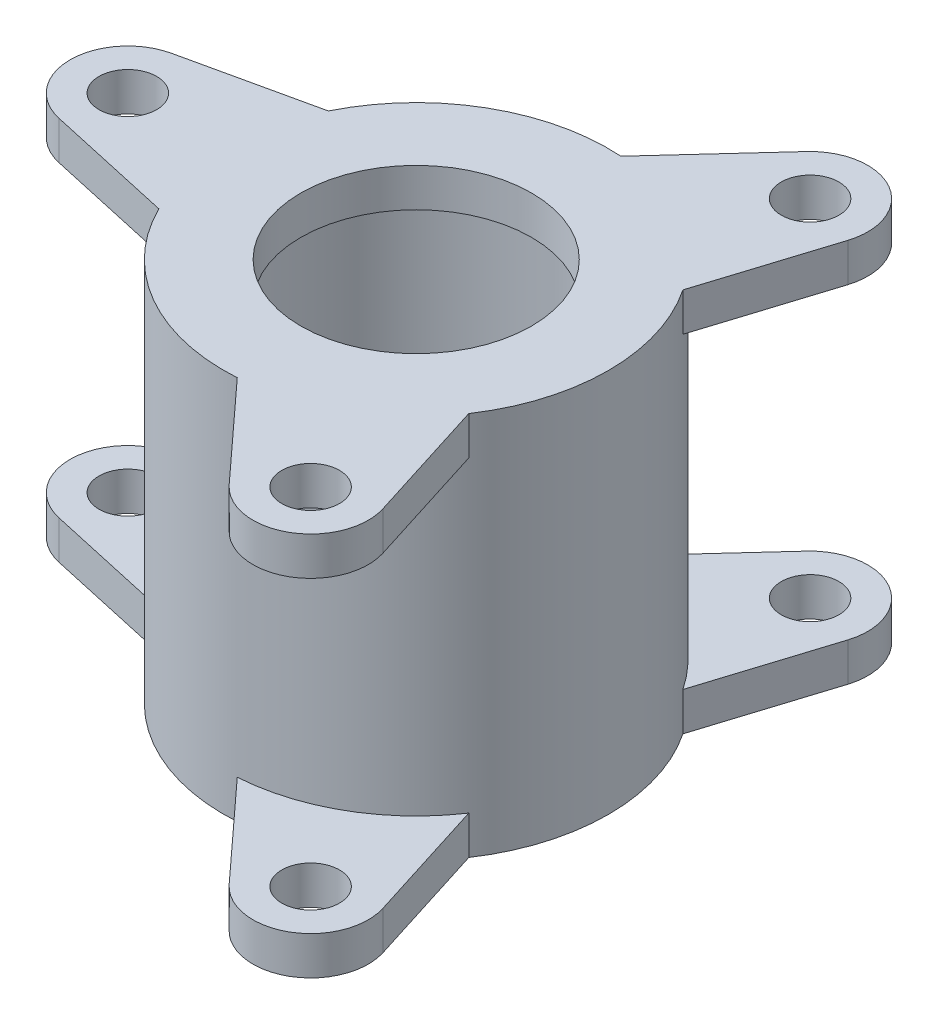
from build123d import *

# Parameters (mm, degrees)
SKETCH2_R               = 7.5
BOSS_EXTRUDE1_DEPTH     = 10
CIRPATTERN1_COUNT       = 3
MIRROR1_COPY_1_SKETCH_R = 7.5
MIRROR1_COPY_1_DEPTH    = 10
MIRROR1_COPY_2_SKETCH_R = 7.5
MIRROR1_COPY_2_DEPTH    = 10


with BuildPart() as part:
    # Sketch1 → Revolve1 (revolve)
    with BuildSketch(Plane.XY):
        Polygon((35, 0), (35, 5), (40, 5), (40, 90), (30, 90), (30, 100), (50, 100), (50, 0), align=None)
    revolve(axis=Axis((0, 0, 0), (0, 1, 0)))

    # Sketch2 → Boss-Extrude1 (add)
    with BuildSketch(Plane(origin=(0, 100, 0), x_dir=(1, 0, 0), z_dir=(0, 1, 0))):
        with BuildLine():
            Line((-78.246594209, 14.644440107), (-44.879398453, 22.041769313))
            ThreePointArc((-44.879398453, 22.041769313), (-50, 0), (-44.879398453, -22.041769313))
            Line((-44.879398453, -22.041769313), (-78.246594209, -14.644440107))
            ThreePointArc((-78.246594209, -14.644440107), (-90, 0), (-78.246594209, 14.644440107))
        make_face()
        with Locations((-75, 0)):
            Circle(SKETCH2_R, mode=Mode.SUBTRACT)
    boss_extrude1 = extrude(amount=-BOSS_EXTRUDE1_DEPTH)

    # CirPattern1: Boss-Extrude1 ×3 about axis
    cirpattern1_axis = Axis((0, 0, 0), (0, 1, 0))
    for i in range(1, CIRPATTERN1_COUNT):
        add(boss_extrude1.rotate(cirpattern1_axis, i * 360 / CIRPATTERN1_COUNT))

    # Mirror1: Boss-Extrude1 across plane
    add(boss_extrude1.mirror(Plane.ZX.offset(50)))

    # Mirror1 copy 1 sketch → Mirror1 copy 1 (add)
    with BuildSketch(Plane(origin=(0, 0, 0), x_dir=(-0.5, 0, -0.866025404), z_dir=(0, -1, 0))):
        with BuildLine():
            Line((-78.246594209, -14.644440107), (-44.879398453, -22.041769313))
            ThreePointArc((-44.879398453, -22.041769313), (-50, 0), (-44.879398453, 22.041769313))
            Line((-44.879398453, 22.041769313), (-78.246594209, 14.644440107))
            ThreePointArc((-78.246594209, 14.644440107), (-90, 0), (-78.246594209, -14.644440107))
        make_face()
        with Locations((-75, 0)):
            Circle(MIRROR1_COPY_1_SKETCH_R, mode=Mode.SUBTRACT)
    extrude(amount=-MIRROR1_COPY_1_DEPTH)

    # Mirror1 copy 2 sketch → Mirror1 copy 2 (add)
    with BuildSketch(Plane(origin=(0, 0, 0), x_dir=(-0.5, 0, 0.866025404), z_dir=(0, -1, 0))):
        with BuildLine():
            Line((-78.246594209, -14.644440107), (-44.879398453, -22.041769313))
            ThreePointArc((-44.879398453, -22.041769313), (-50, 0), (-44.879398453, 22.041769313))
            Line((-44.879398453, 22.041769313), (-78.246594209, 14.644440107))
            ThreePointArc((-78.246594209, 14.644440107), (-90, 0), (-78.246594209, -14.644440107))
        make_face()
        with Locations((-75, 0)):
            Circle(MIRROR1_COPY_2_SKETCH_R, mode=Mode.SUBTRACT)
    extrude(amount=-MIRROR1_COPY_2_DEPTH)


solid = part.part
